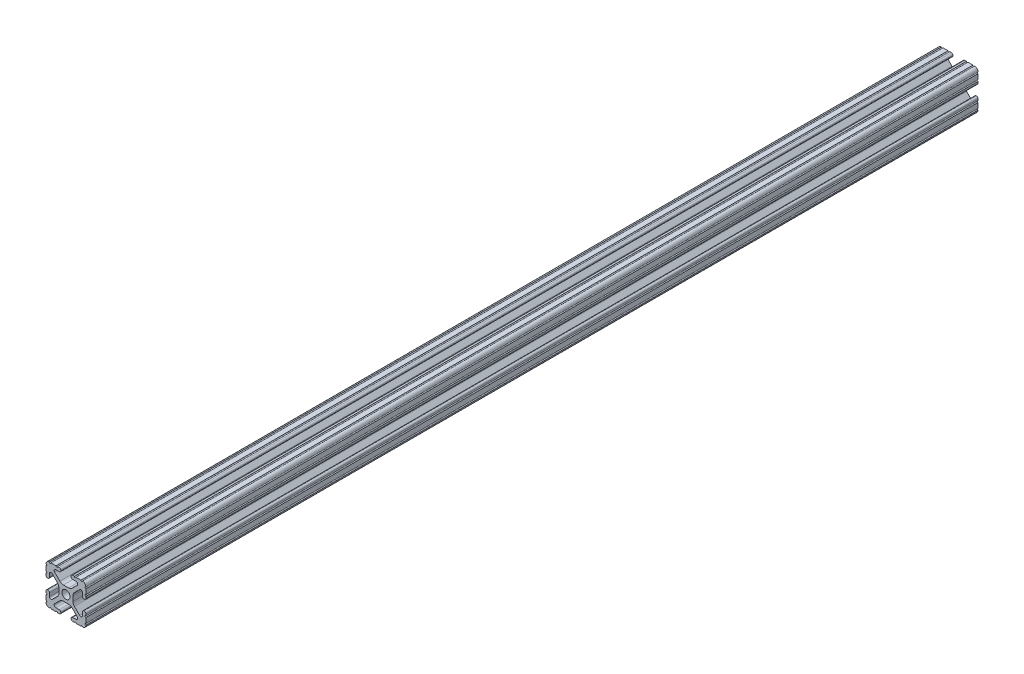
from build123d import *

# Parameters (mm, degrees)
SKETCH3_R                = 2.6035
BOSS_EXTRUDE1_DEPTH      = 284.150642
BOSS_EXTRUDE1_DEPTH_BACK = 284.150642


with BuildPart() as part:
    # Sketch3 → Boss-Extrude1 (new body, two sides)
    with BuildSketch(Plane.XY) as boss_extrude1_sk:
        with BuildLine():
            Line((-7.179650497, -8.645192506), (-3.952270251, -5.423690499))
            ThreePointArc((-3.952270251, -5.423690499), (-2.922936451, -4.736929036), (-1.709253557, -4.4958))
            Line((-1.709253557, -4.4958), (1.709253557, -4.4958))
            ThreePointArc((1.709253557, -4.4958), (2.922936451, -4.736929036), (3.952270251, -5.423690499))
            Line((3.952270251, -5.423690499), (7.179650497, -8.645192506))
            ThreePointArc((7.179650497, -8.645192506), (7.41473083, -9.822813117), (6.416408329, -10.4902))
            Line((6.416408329, -10.4902), (4.287512407, -10.4902))
            ThreePointArc((4.287512407, -10.4902), (3.54574862, -10.79744862), (3.2385, -11.539212407))
            Line((3.2385, -11.539212407), (3.2385, -11.650987593))
            ThreePointArc((3.2385, -11.650987593), (3.54574862, -12.39275138), (4.287512407, -12.7))
            Line((4.287512407, -12.7), (5.317126718, -12.7))
            ThreePointArc((5.317126718, -12.7), (5.825126718, -12.192), (6.333126718, -12.7))
            Line((6.333126718, -12.7), (9.550443118, -12.7))
            ThreePointArc((9.550443118, -12.7), (10.058366869, -12.192000006), (10.566443095, -12.699847501))
            ThreePointArc((10.566443095, -12.699847501), (12.082537762, -12.08250727), (12.699846982, -10.566399977))
            ThreePointArc((12.699846982, -10.566399977), (12.192000006, -10.058323491), (12.7, -9.5504))
            Line((12.7, -9.5504), (12.7, -6.3330836))
            ThreePointArc((12.7, -6.3330836), (12.192, -5.8250836), (12.7, -5.3170836))
            Line((12.7, -5.3170836), (12.7, -4.287469289))
            ThreePointArc((12.7, -4.287469289), (12.39275138, -3.545705502), (11.650987593, -3.238456882))
            Line((11.650987593, -3.238456882), (11.539212407, -3.238456882))
            ThreePointArc((11.539212407, -3.238456882), (10.79744862, -3.545705502), (10.4902, -4.287469289))
            Line((10.4902, -4.287469289), (10.4902, -6.402089023))
            ThreePointArc((10.4902, -6.402089023), (9.856505071, -7.351067942), (8.737131347, -7.129408934))
            Line((8.737131347, -7.129408934), (5.441005833, -3.840816462))
            ThreePointArc((5.441005833, -3.840816462), (4.750877967, -2.809883091), (4.5085, -1.593185507))
            Line((4.5085, -1.593185507), (4.5085, 1.593185507))
            ThreePointArc((4.5085, 1.593185507), (4.750877967, 2.809883091), (5.441005833, 3.840816462))
            Line((5.441005833, 3.840816462), (8.737131347, 7.129408934))
            ThreePointArc((8.737131347, 7.129408934), (9.856505071, 7.351067942), (10.4902, 6.402089023))
            Line((10.4902, 6.402089023), (10.4902, 4.287469289))
            ThreePointArc((10.4902, 4.287469289), (10.79744862, 3.545705502), (11.539212407, 3.238456882))
            Line((11.539212407, 3.238456882), (11.650987593, 3.238456882))
            ThreePointArc((11.650987593, 3.238456882), (12.39275138, 3.545705502), (12.7, 4.287469289))
            Line((12.7, 4.287469289), (12.7, 5.3170836))
            ThreePointArc((12.7, 5.3170836), (12.192, 5.8250836), (12.7, 6.3330836))
            Line((12.7, 6.3330836), (12.7, 9.5504))
            ThreePointArc((12.7, 9.5504), (12.192000006, 10.058323491), (12.699846982, 10.566399977))
            ThreePointArc((12.699846982, 10.566399977), (12.082537762, 12.08250727), (10.566443095, 12.699847501))
            ThreePointArc((10.566443095, 12.699847501), (10.058366869, 12.192000006), (9.550443118, 12.7))
            Line((9.550443118, 12.7), (6.333126718, 12.7))
            ThreePointArc((6.333126718, 12.7), (5.825126718, 12.192), (5.317126718, 12.7))
            Line((5.317126718, 12.7), (4.287512407, 12.7))
            ThreePointArc((4.287512407, 12.7), (3.54574862, 12.39275138), (3.2385, 11.650987593))
            Line((3.2385, 11.650987593), (3.2385, 11.539212407))
            ThreePointArc((3.2385, 11.539212407), (3.54574862, 10.79744862), (4.287512407, 10.4902))
            Line((4.287512407, 10.4902), (6.476788598, 10.4902))
            ThreePointArc((6.476788598, 10.4902), (7.432222385, 9.85140422), (7.207036008, 8.724370562))
            Line((7.207036008, 8.724370562), (3.898272566, 5.423169045))
            ThreePointArc((3.898272566, 5.423169045), (2.869120213, 4.736787962), (1.655778399, 4.4958))
            Line((1.655778399, 4.4958), (-1.655778399, 4.4958))
            ThreePointArc((-1.655778399, 4.4958), (-2.869120213, 4.736787962), (-3.898272566, 5.423169045))
            Line((-3.898272566, 5.423169045), (-7.207036008, 8.724370562))
            ThreePointArc((-7.207036008, 8.724370562), (-7.432222385, 9.85140422), (-6.476788598, 10.4902))
            Line((-6.476788598, 10.4902), (-4.287512407, 10.4902))
            ThreePointArc((-4.287512407, 10.4902), (-3.54574862, 10.79744862), (-3.2385, 11.539212407))
            Line((-3.2385, 11.539212407), (-3.2385, 11.650987593))
            ThreePointArc((-3.2385, 11.650987593), (-3.54574862, 12.39275138), (-4.287512407, 12.7))
            Line((-4.287512407, 12.7), (-5.317126718, 12.7))
            ThreePointArc((-5.317126718, 12.7), (-5.825126718, 12.192), (-6.333126718, 12.7))
            Line((-6.333126718, 12.7), (-9.550443118, 12.7))
            ThreePointArc((-9.550443118, 12.7), (-10.058366869, 12.192000006), (-10.566443095, 12.699847501))
            ThreePointArc((-10.566443095, 12.699847501), (-12.082537762, 12.08250727), (-12.699846982, 10.566399977))
            ThreePointArc((-12.699846982, 10.566399977), (-12.192000006, 10.058323491), (-12.7, 9.5504))
            Line((-12.7, 9.5504), (-12.7, 6.3330836))
            ThreePointArc((-12.7, 6.3330836), (-12.192, 5.8250836), (-12.7, 5.3170836))
            Line((-12.7, 5.3170836), (-12.7, 4.287469289))
            ThreePointArc((-12.7, 4.287469289), (-12.39275138, 3.545705502), (-11.650987593, 3.238456882))
            Line((-11.650987593, 3.238456882), (-11.539212407, 3.238456882))
            ThreePointArc((-11.539212407, 3.238456882), (-10.79744862, 3.545705502), (-10.4902, 4.287469289))
            Line((-10.4902, 4.287469289), (-10.4902, 6.402089023))
            ThreePointArc((-10.4902, 6.402089023), (-9.856505071, 7.351067942), (-8.737131347, 7.129408934))
            Line((-8.737131347, 7.129408934), (-5.441005833, 3.840816462))
            ThreePointArc((-5.441005833, 3.840816462), (-4.750877967, 2.809883091), (-4.5085, 1.593185507))
            Line((-4.5085, 1.593185507), (-4.5085, -1.593185507))
            ThreePointArc((-4.5085, -1.593185507), (-4.750877967, -2.809883091), (-5.441005833, -3.840816462))
            Line((-5.441005833, -3.840816462), (-8.737131347, -7.129408934))
            ThreePointArc((-8.737131347, -7.129408934), (-9.856505071, -7.351067942), (-10.4902, -6.402089023))
            Line((-10.4902, -6.402089023), (-10.4902, -4.287469289))
            ThreePointArc((-10.4902, -4.287469289), (-10.79744862, -3.545705502), (-11.539212407, -3.238456882))
            Line((-11.539212407, -3.238456882), (-11.650987593, -3.238456882))
            ThreePointArc((-11.650987593, -3.238456882), (-12.39275138, -3.545705502), (-12.7, -4.287469289))
            Line((-12.7, -4.287469289), (-12.7, -5.3170836))
            ThreePointArc((-12.7, -5.3170836), (-12.192, -5.8250836), (-12.7, -6.3330836))
            Line((-12.7, -6.3330836), (-12.7, -9.5504))
            ThreePointArc((-12.7, -9.5504), (-12.192000006, -10.058323491), (-12.699846982, -10.566399977))
            ThreePointArc((-12.699846982, -10.566399977), (-12.082537762, -12.08250727), (-10.566443095, -12.699847501))
            ThreePointArc((-10.566443095, -12.699847501), (-10.058366869, -12.192000006), (-9.550443118, -12.7))
            Line((-9.550443118, -12.7), (-6.333126718, -12.7))
            ThreePointArc((-6.333126718, -12.7), (-5.825126718, -12.192), (-5.317126718, -12.7))
            Line((-5.317126718, -12.7), (-4.287512407, -12.7))
            ThreePointArc((-4.287512407, -12.7), (-3.54574862, -12.39275138), (-3.2385, -11.650987593))
            Line((-3.2385, -11.650987593), (-3.2385, -11.539212407))
            ThreePointArc((-3.2385, -11.539212407), (-3.54574862, -10.79744862), (-4.287512407, -10.4902))
            Line((-4.287512407, -10.4902), (-6.416408329, -10.4902))
            ThreePointArc((-6.416408329, -10.4902), (-7.41473083, -9.822813117), (-7.179650497, -8.645192506))
        make_face()
        Circle(SKETCH3_R, mode=Mode.SUBTRACT)
    extrude(amount=BOSS_EXTRUDE1_DEPTH)
    extrude(boss_extrude1_sk.sketch, amount=-BOSS_EXTRUDE1_DEPTH_BACK)


solid = part.part
